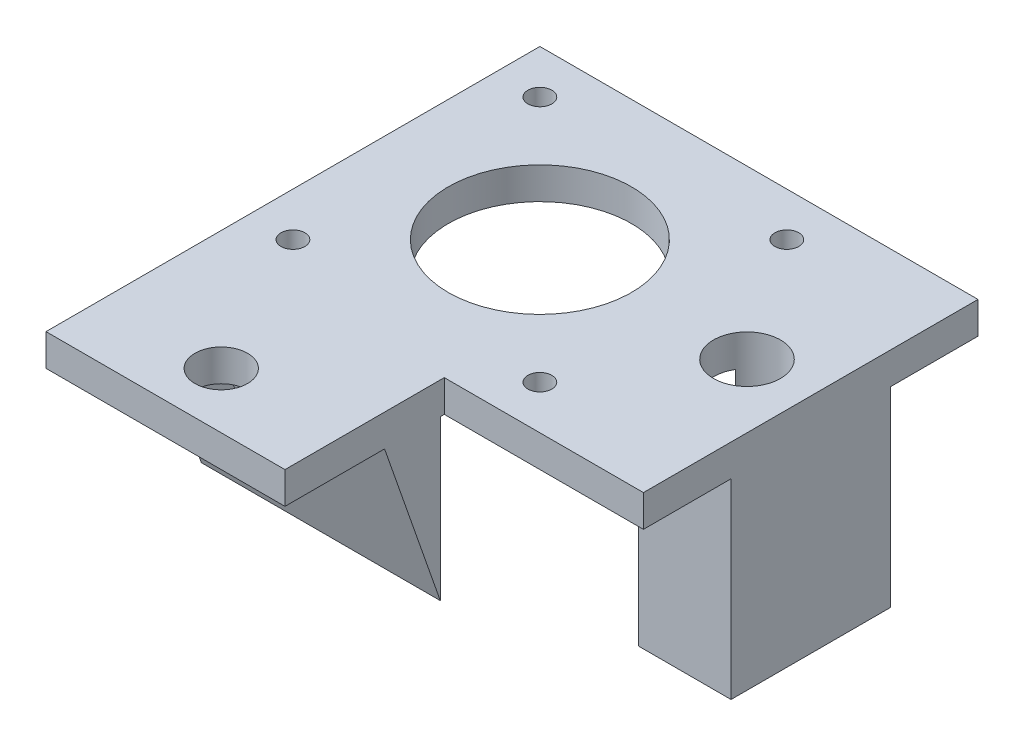
from build123d import *

# Parameters (mm, degrees)
SKETCH1_R           = 4.2
SKETCH1_R_2         = 11.5
SKETCH1_R_3         = 1.5
SKETCH1_R_4         = 3.3
BOSS_EXTRUDE1_DEPTH = 4
BOSS_EXTRUDE2_DEPTH = 20
SKETCH3_W           = 11.6
SKETCH3_H           = 20
BOSS_EXTRUDE3_DEPTH = 4
BOSS_EXTRUDE4_DEPTH = 30
SKETCH5_R           = 8.75
CUT_EXTRUDE1_DEPTH  = 25


with BuildPart() as part:
    # Sketch1 → Boss-Extrude1 (new body)
    with BuildSketch(Plane(origin=(0, 0, 0), x_dir=(1, 0, 0), z_dir=(0, 1, 0))):
        Polygon((0, 0), (0, 42), (55, 42), (55, 0), (30, 0), (30, -20), (0, -20), align=None)
        with Locations((47, 21)):
            Circle(SKETCH1_R, mode=Mode.SUBTRACT)
        with Locations((21, 21)):
            Circle(SKETCH1_R_2, mode=Mode.SUBTRACT)
        with Locations((5.5, 36.5)):
            Circle(SKETCH1_R_3, mode=Mode.SUBTRACT)
        with Locations((36.5, 36.5)):
            Circle(SKETCH1_R_3, mode=Mode.SUBTRACT)
        with Locations((5.5, 5.5)):
            Circle(SKETCH1_R_3, mode=Mode.SUBTRACT)
        with Locations((36.5, 5.5)):
            Circle(SKETCH1_R_3, mode=Mode.SUBTRACT)
        with Locations((15, -13)):
            Circle(SKETCH1_R_4, mode=Mode.SUBTRACT)
    extrude(amount=BOSS_EXTRUDE1_DEPTH)

    # Sketch2 → Boss-Extrude2 (add)
    with BuildSketch(Plane.XZ):
        with BuildLine():
            ThreePointArc((53.6, -21), (50.146426545, -15.198276118), (43.4, -15.468273326))
            Line((43.4, -15.468273326), (43.4, -18.836669235))
            ThreePointArc((43.4, -18.836669235), (48.122497216, -16.952778731), (51.2, -21))
            ThreePointArc((51.2, -21), (48.122497216, -25.047221269), (43.4, -23.163330765))
            Line((43.4, -23.163330765), (43.4, -26.531726674))
            ThreePointArc((43.4, -26.531726674), (50.146426545, -26.801723882), (53.6, -21))
        make_face()
        with BuildLine():
            Line((55, -11), (43.4, -11))
            Line((43.4, -11), (43.4, -15.468273326))
            ThreePointArc((43.4, -15.468273326), (50.146426545, -15.198276118), (53.6, -21))
            ThreePointArc((53.6, -21), (50.146426545, -26.801723882), (43.4, -26.531726674))
            Line((43.4, -26.531726674), (43.4, -31))
            Line((43.4, -31), (55, -31))
            Line((55, -31), (55, -11))
        make_face()
    extrude(amount=BOSS_EXTRUDE2_DEPTH)

    # Sketch3 → Boss-Extrude3 (add)
    with BuildSketch(Plane.XZ.offset(20)):
        with Locations((49.2, -21)):
            Rectangle(SKETCH3_W, SKETCH3_H)
    extrude(amount=BOSS_EXTRUDE3_DEPTH)

    # Sketch4 → Boss-Extrude4 (add)
    with BuildSketch(Plane.ZY):
        Polygon((0.5, 0), (7.5, 0), (0.5, -20), align=None)
    extrude(amount=-BOSS_EXTRUDE4_DEPTH)

    # Sketch5 → Cut-Extrude1 (cut, through all)
    with BuildSketch(Plane.XZ):
        with Locations((15, 13)):
            Circle(SKETCH5_R)
    extrude(amount=CUT_EXTRUDE1_DEPTH, mode=Mode.SUBTRACT)


solid = part.part
